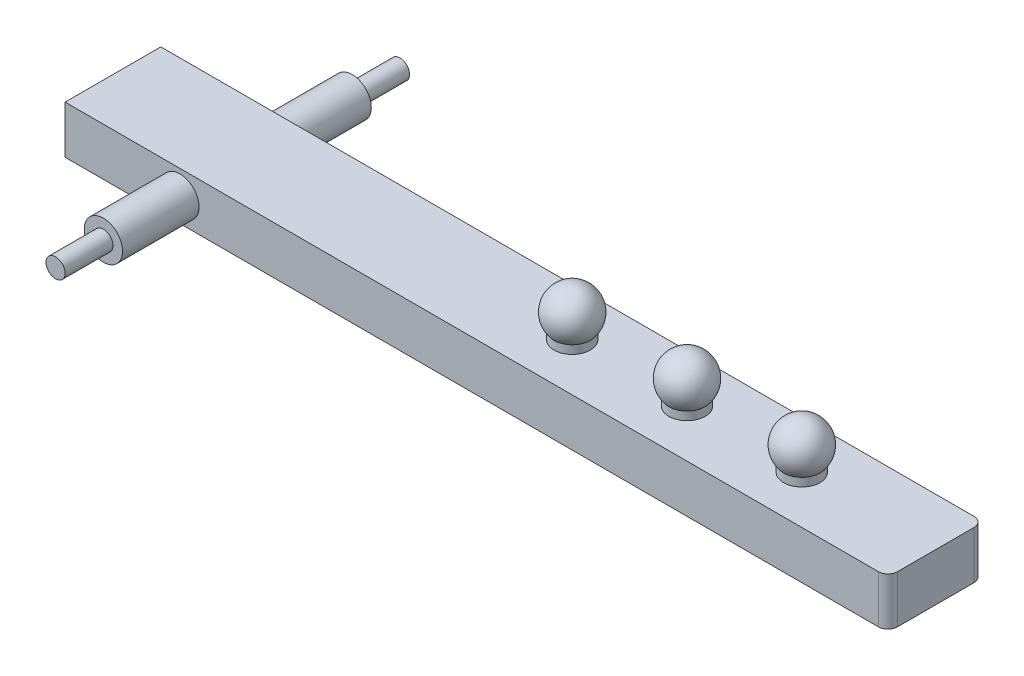
from build123d import *

# Parameters (mm, degrees)
SKETCH_1_R              = 20
EXTRUDE_1_DEPTH         = 130
SKETCH_2_W              = 860
SKETCH_2_H              = 50
EXTRUDE_2_DEPTH         = 50
SKETCH_3_R              = 10
EXTRUDE_3_DEPTH         = 50
PATTERN_LINEAR_16_COUNT = 3
PATTERN_LINEAR_16_PITCH = 120
FILLET_1_R              = 10


with BuildPart() as part:
    # 草图1 → 凸台-拉伸1 (new body, symmetric)
    with BuildSketch(Plane.XY):
        Circle(SKETCH_1_R)
    extrude(amount=EXTRUDE_1_DEPTH, both=True)

    # 草图2 → 凸台-拉伸2 (add, symmetric)
    with BuildSketch(Plane.XY):
        with Locations((310, 0)):
            Rectangle(SKETCH_2_W, SKETCH_2_H)
    extrude(amount=EXTRUDE_2_DEPTH, both=True)

    # 草图3 → 凸台-拉伸3 (add)
    with BuildSketch(Plane.XY.offset(130)):
        Circle(SKETCH_3_R)
    extrude_3 = extrude(amount=EXTRUDE_3_DEPTH)

    # 镜向1: 凸台-拉伸3 across plane
    add(extrude_3.mirror(Plane.XY))

    # 草图6 → 旋转3 (revolve)
    with BuildSketch(Plane.XY):
        with BuildLine():
            Line((360, 75), (360, 50))
            Line((360, 50), (360, 25))
            Line((360, 25), (378.993679067, 25))
            Line((378.993679067, 25), (378.993679067, 33.744534596))
            ThreePointArc((378.993679067, 33.744534596), (382.708881909, 60.454983618), (360, 75))
        make_face()
    revolve_3 = revolve(axis=Axis((360, 25, 0), (0, 1, 0)))

    # 阵列(线性)16: 旋转3 ×3
    with Locations(*[(i * PATTERN_LINEAR_16_PITCH, 0, 0) for i in range(1, PATTERN_LINEAR_16_COUNT)]):
        add(revolve_3)

    # 圆角1
    fillet_1_edges = [part.edges().sort_by_distance(p)[0] for p in [
        (740, 0, -50),
        (740, 0, 50),
    ]]
    fillet(fillet_1_edges, radius=FILLET_1_R)


solid = part.part
